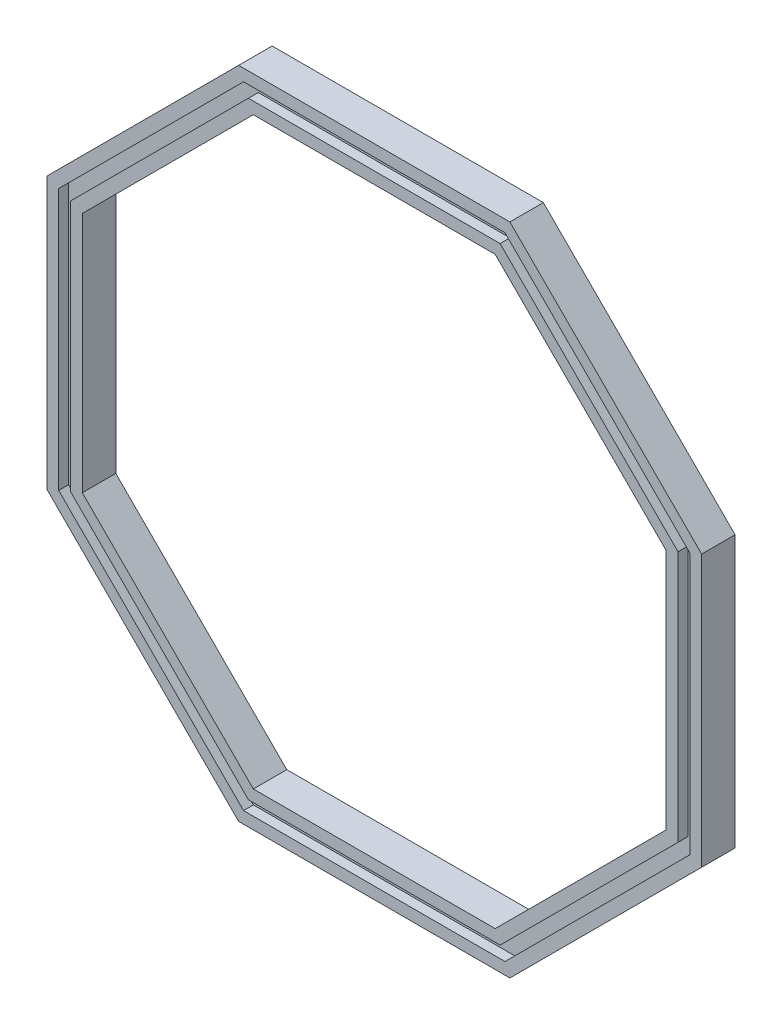
from build123d import *

# Parameters (mm, degrees)
EXTRUDE_2_DEPTH     = 3.4
CUT_EXTRUDE_3_DEPTH = 1


with BuildPart() as part:
    # 스케치7 → 보스-돌출2 (new body)
    with BuildSketch(Plane.XY):
        Polygon((-33.25966317, -13.776603565), (-13.776603565, -33.25966317), (13.776603565, -33.25966317), (33.25966317, -13.776603565), (33.25966317, 13.776603565), (13.776603565, 33.25966317), (-13.776603565, 33.25966317), (-33.25966317, 13.776603565), align=None)
        Polygon((-13.27954729, -32.05966317), (13.27954729, -32.05966317), (32.05966317, -13.27954729), (32.05966317, 13.27954729), (13.27954729, 32.05966317), (-13.27954729, 32.05966317), (-32.05966317, 13.27954729), (-32.05966317, -13.27954729), align=None, mode=Mode.SUBTRACT)
        Polygon((-32.05966317, -13.27954729), (-13.27954729, -32.05966317), (13.27954729, -32.05966317), (32.05966317, -13.27954729), (32.05966317, 13.27954729), (13.27954729, 32.05966317), (-13.27954729, 32.05966317), (-32.05966317, 13.27954729), align=None)
        Polygon((-12.782491015, -30.85966317), (12.782491015, -30.85966317), (30.85966317, -12.782491015), (30.85966317, 12.782491015), (12.782491015, 30.85966317), (-12.782491015, 30.85966317), (-30.85966317, 12.782491015), (-30.85966317, -12.782491015), align=None, mode=Mode.SUBTRACT)
        Polygon((-30.85966317, -12.782491015), (-12.782491015, -30.85966317), (12.782491015, -30.85966317), (30.85966317, -12.782491015), (30.85966317, 12.782491015), (12.782491015, 30.85966317), (-12.782491015, 30.85966317), (-30.85966317, 12.782491015), align=None)
        Polygon((-12.285434741, -29.65966317), (12.285434741, -29.65966317), (29.65966317, -12.285434741), (29.65966317, 12.285434741), (12.285434741, 29.65966317), (-12.285434741, 29.65966317), (-29.65966317, 12.285434741), (-29.65966317, -12.285434741), align=None, mode=Mode.SUBTRACT)
    extrude(amount=-EXTRUDE_2_DEPTH)

    # 스케치9 → 컷-돌출3 (cut)
    with BuildSketch(Plane.XY):
        Polygon((13.27954729, -32.05966317), (32.05966317, -13.27954729), (32.05966317, 13.27954729), (13.27954729, 32.05966317), (-13.27954729, 32.05966317), (-32.05966317, 13.27954729), (-32.05966317, -13.27954729), (-13.27954729, -32.05966317), align=None)
        Polygon((12.782491015, -30.85966317), (30.85966317, -12.782491015), (30.85966317, 12.782491015), (12.782491015, 30.85966317), (-12.782491015, 30.85966317), (-30.85966317, 12.782491015), (-30.85966317, -12.782491015), (-12.782491015, -30.85966317), align=None, mode=Mode.SUBTRACT)
    cut_extrude_3 = extrude(amount=-CUT_EXTRUDE_3_DEPTH, mode=Mode.SUBTRACT)

    # 대칭 복사4: 컷-돌출3 across plane
    add(cut_extrude_3.mirror(Plane.XY.offset(-1.7)), mode=Mode.SUBTRACT)


solid = part.part
